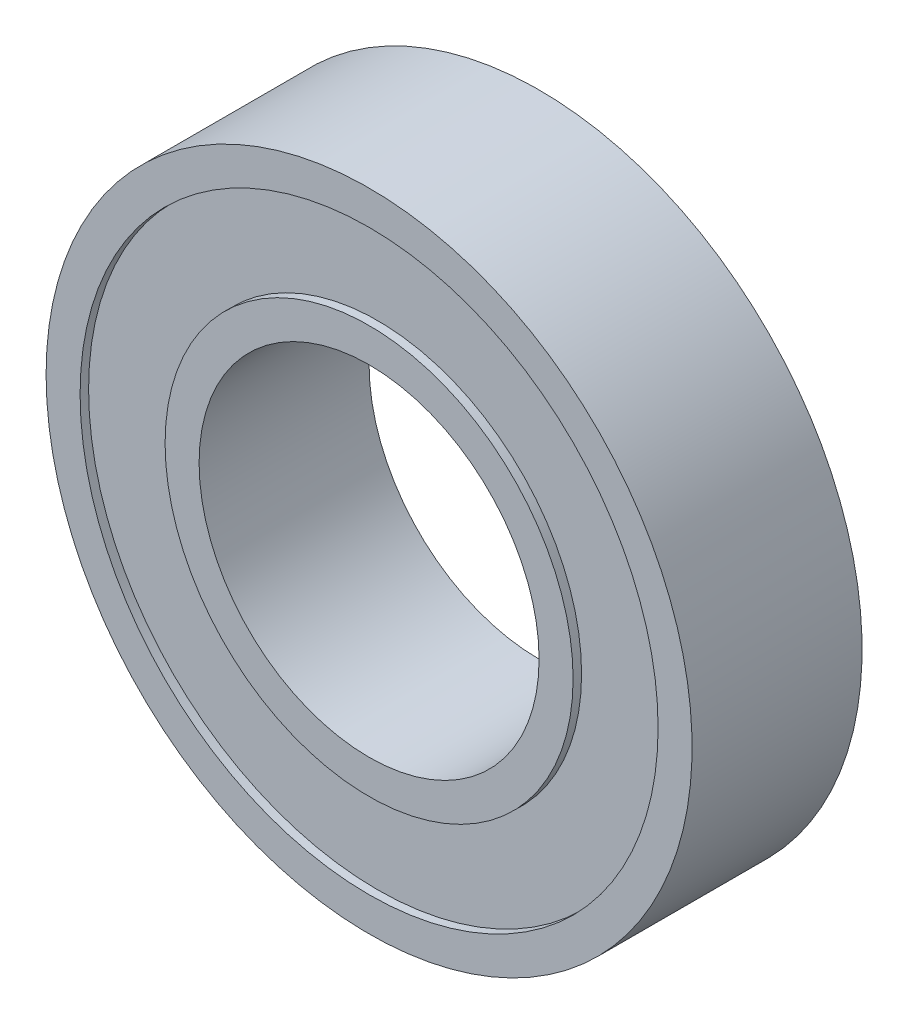
from build123d import *


with BuildPart() as part:
    # Sketch1 → Revolve1 (revolve)
    with BuildSketch(Plane(origin=(0, 0, 0), x_dir=(1, 0, 0), z_dir=(0, 1, 0))):
        Polygon((5, -2.5), (6, -2.5), (6, -2.25), (8.5, -2.25), (8.5, -2.5), (9.5, -2.5), (9.5, 2.5), (8.5, 2.5), (8.5, 2.25), (6, 2.25), (6, 2.5), (5, 2.5), align=None)
    revolve(axis=Axis((0, 0, -2.5), (0, 0, 1)))


solid = part.part
